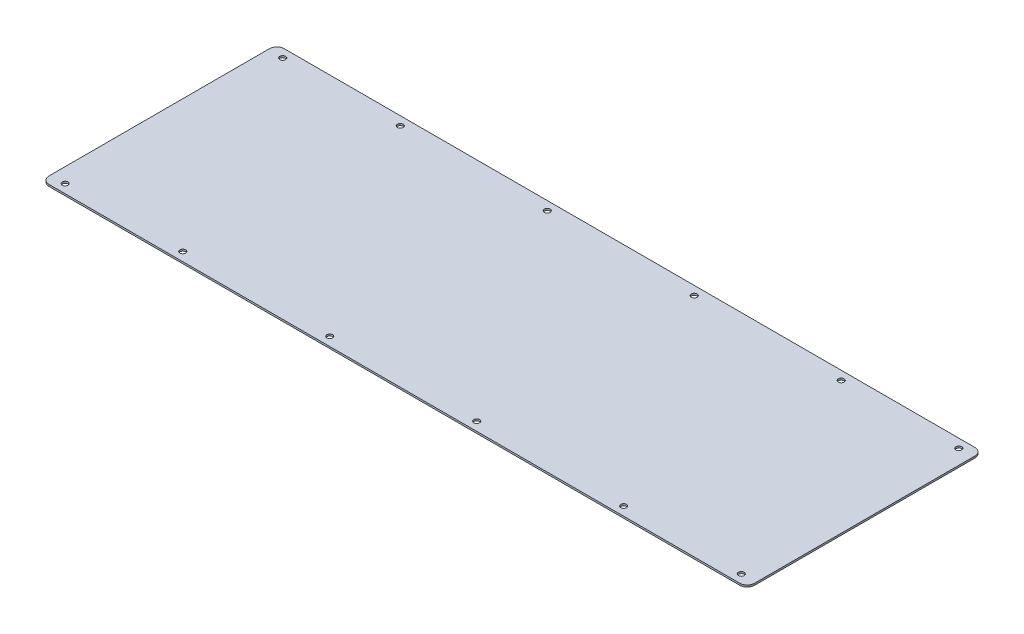
from build123d import *

# Parameters (mm, degrees)
SKETCH1_W           = 609.6
SKETCH1_H           = 203.2
BOSS_EXTRUDE1_DEPTH = 1.5875
FILLET1_R           = 6.35
SKETCH2_R           = 2.4892
CUT_EXTRUDE1_DEPTH  = 2.5875


with BuildPart() as part:
    # Sketch1 → Boss-Extrude1 (new body)
    with BuildSketch(Plane(origin=(0, 0, 0), x_dir=(1, 0, 0), z_dir=(0, 1, 0))):
        with Locations((304.8, 101.6)):
            Rectangle(SKETCH1_W, SKETCH1_H)
    extrude(amount=BOSS_EXTRUDE1_DEPTH)

    # Fillet1
    fillet1_edges = [part.edges().sort_by_distance(p)[0] for p in [
        (0, 0.79375, -203.2),
        (609.6, 0.79375, -203.2),
        (609.6, 0.79375, 0),
        (0, 0.79375, 0),
    ]]
    fillet(fillet1_edges, radius=FILLET1_R)

    # Sketch2 → Cut-Extrude1 (cut, through all)
    with BuildSketch(Plane(origin=(0, 1.5875, 0), x_dir=(1, 0, 0), z_dir=(0, 1, 0))):
        with Locations((12.7, 7.62)):
            Circle(SKETCH2_R)
        with Locations((596.9, 7.62)):
            Circle(SKETCH2_R)
        with Locations((114.3, 7.62)):
            Circle(SKETCH2_R)
        with Locations((495.3, 7.62)):
            Circle(SKETCH2_R)
        with Locations((241.3, 7.62)):
            Circle(SKETCH2_R)
        with Locations((368.3, 7.62)):
            Circle(SKETCH2_R)
        with Locations((368.3, 195.58)):
            Circle(SKETCH2_R)
        with Locations((241.3, 195.58)):
            Circle(SKETCH2_R)
        with Locations((495.3, 195.58)):
            Circle(SKETCH2_R)
        with Locations((114.3, 195.58)):
            Circle(SKETCH2_R)
        with Locations((596.9, 195.58)):
            Circle(SKETCH2_R)
        with Locations((12.7, 195.58)):
            Circle(SKETCH2_R)
    extrude(amount=-CUT_EXTRUDE1_DEPTH, mode=Mode.SUBTRACT)


solid = part.part
